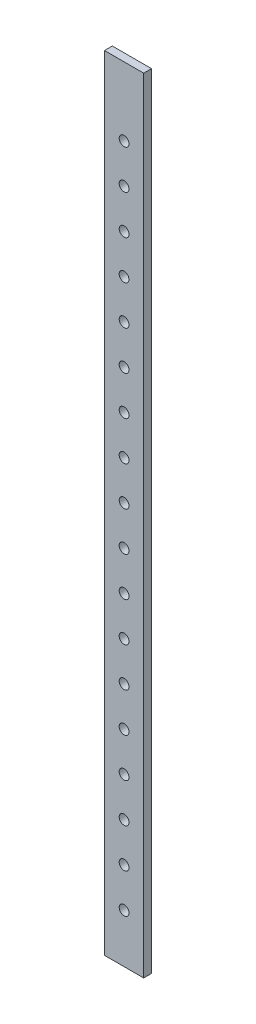
from build123d import *

# Parameters (mm, degrees)
SKETCH_1_W          = 20
SKETCH_1_H          = 4
EXTRUDE_1_DEPTH     = 400
SKETCH_2_R          = 2.5
CUT_EXTRUDE_1_DEPTH = 5


with BuildPart() as part:
    # Эскиз1 → Бобышка-Вытянуть1 (new body)
    with BuildSketch(Plane(origin=(0, 0, 0), x_dir=(1, 0, 0), z_dir=(0, 1, 0))):
        Rectangle(SKETCH_1_W, SKETCH_1_H)
    extrude(amount=EXTRUDE_1_DEPTH)

    # Эскиз2 → Вырез-Вытянуть1 (cut, through all)
    with BuildSketch(Plane.XY.offset(2)):
        with Locations((0, 25)):
            Circle(SKETCH_2_R)
        with Locations((0, 45)):
            Circle(SKETCH_2_R)
        with Locations((0, 65)):
            Circle(SKETCH_2_R)
        with Locations((0, 85)):
            Circle(SKETCH_2_R)
        with Locations((0, 105)):
            Circle(SKETCH_2_R)
        with Locations((0, 125)):
            Circle(SKETCH_2_R)
        with Locations((0, 145)):
            Circle(SKETCH_2_R)
        with Locations((0, 165)):
            Circle(SKETCH_2_R)
        with Locations((0, 185)):
            Circle(SKETCH_2_R)
        with Locations((0, 205)):
            Circle(SKETCH_2_R)
        with Locations((0, 225)):
            Circle(SKETCH_2_R)
        with Locations((0, 245)):
            Circle(SKETCH_2_R)
        with Locations((0, 265)):
            Circle(SKETCH_2_R)
        with Locations((0, 285)):
            Circle(SKETCH_2_R)
        with Locations((0, 305)):
            Circle(SKETCH_2_R)
        with Locations((0, 325)):
            Circle(SKETCH_2_R)
        with Locations((0, 345)):
            Circle(SKETCH_2_R)
        with Locations((0, 365)):
            Circle(SKETCH_2_R)
    extrude(amount=-CUT_EXTRUDE_1_DEPTH, mode=Mode.SUBTRACT)


solid = part.part
